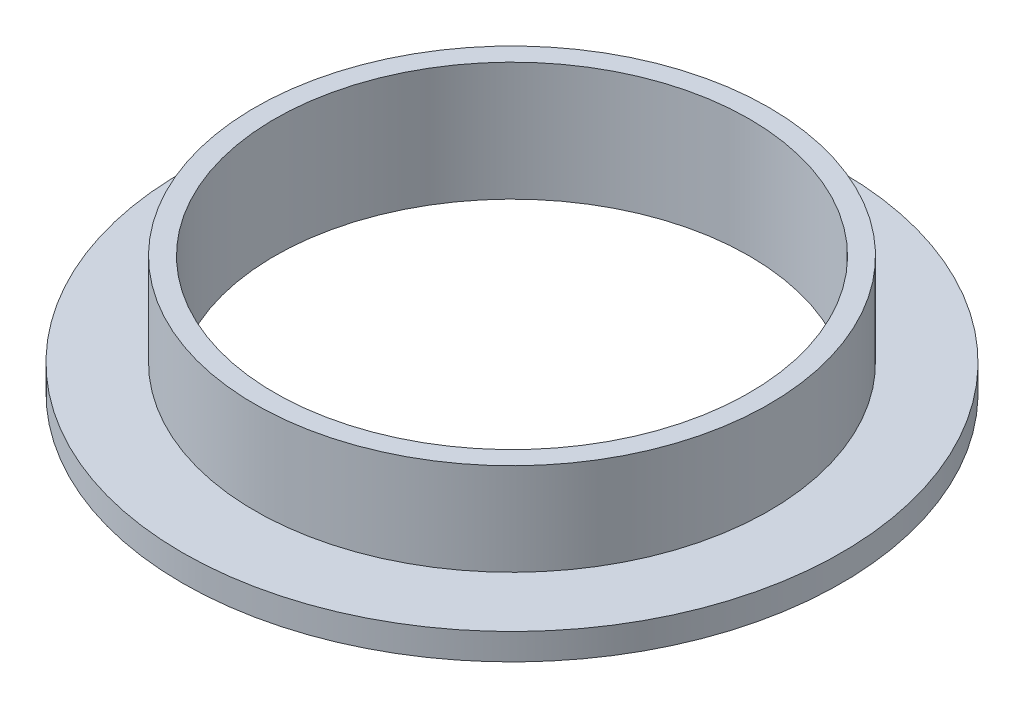
from build123d import *


with BuildPart() as part:
    # Sketch1 → Revolve1 (revolve)
    with BuildSketch(Plane.XY):
        Polygon((18, 0), (25, 0), (25, 2), (19.5, 2), (19.5, 9), (18, 9), align=None)
    revolve(axis=Axis((0, 0, 0), (0, 1, 0)))


solid = part.part
